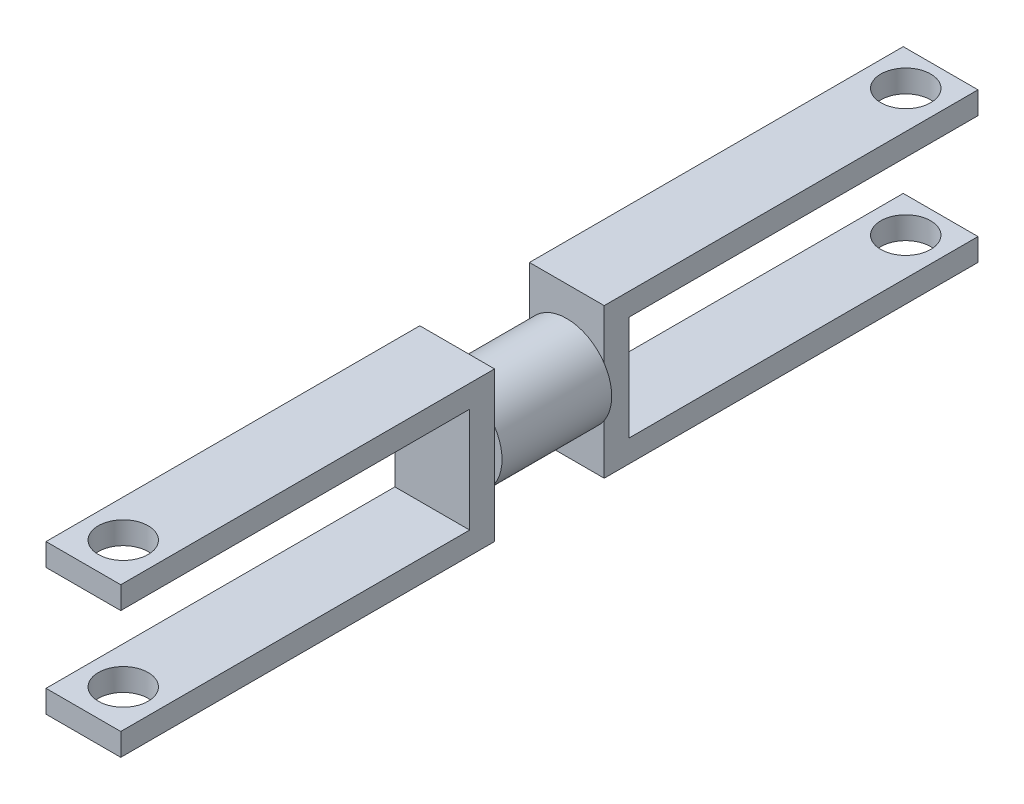
from build123d import *

# Parameters (mm, degrees)
SKETCH_1_R          = 3.6
EXTRUDE_1_DEPTH     = 8.8
SKETCH_2_W          = 6
SKETCH_2_H          = 12
EXTRUDE_2_DEPTH     = 30
SKETCH_4_W          = 6
SKETCH_4_H          = 12
EXTRUDE_3_DEPTH     = 30
SKETCH_3_R          = 2
CUT_EXTRUDE_1_DEPTH = 30
SKETCH_5_W          = 6
SKETCH_5_H          = 8.4
CUT_EXTRUDE_2_DEPTH = 28
SKETCH_6_W          = 6
SKETCH_6_H          = 8.4
CUT_EXTRUDE_3_DEPTH = 28


with BuildPart() as part:
    # 草图1 → 凸台-拉伸1 (new body)
    with BuildSketch(Plane.XY):
        Circle(SKETCH_1_R)
    extrude(amount=EXTRUDE_1_DEPTH)

    # 草图2 → 凸台-拉伸2 (add)
    with BuildSketch(Plane.XY.offset(8.8)):
        Rectangle(SKETCH_2_W, SKETCH_2_H)
    extrude(amount=EXTRUDE_2_DEPTH)

    # 草图4 → 凸台-拉伸3 (add)
    with BuildSketch(Plane(origin=(0, 0, 0), x_dir=(-1, 0, 0), z_dir=(0, 0, -1))):
        Rectangle(SKETCH_4_W, SKETCH_4_H)
    extrude(amount=EXTRUDE_3_DEPTH)

    # 草图3 → 切除-拉伸1 (cut)
    with BuildSketch(Plane(origin=(0, 6, 0), x_dir=(1, 0, 0), z_dir=(0, 1, 0))):
        with Locations((0, -35.6)):
            Circle(SKETCH_3_R)
        with Locations((0, 27.2)):
            Circle(SKETCH_3_R)
    extrude(amount=-CUT_EXTRUDE_1_DEPTH, mode=Mode.SUBTRACT)

    # 草图5 → 切除-拉伸2 (cut)
    with BuildSketch(Plane(origin=(0, 0, -30), x_dir=(-1, 0, 0), z_dir=(0, 0, -1))):
        Rectangle(SKETCH_5_W, SKETCH_5_H)
    extrude(amount=-CUT_EXTRUDE_2_DEPTH, mode=Mode.SUBTRACT)

    # 草图6 → 切除-拉伸3 (cut)
    with BuildSketch(Plane.XY.offset(38.8)):
        Rectangle(SKETCH_6_W, SKETCH_6_H)
    extrude(amount=-CUT_EXTRUDE_3_DEPTH, mode=Mode.SUBTRACT)


solid = part.part
